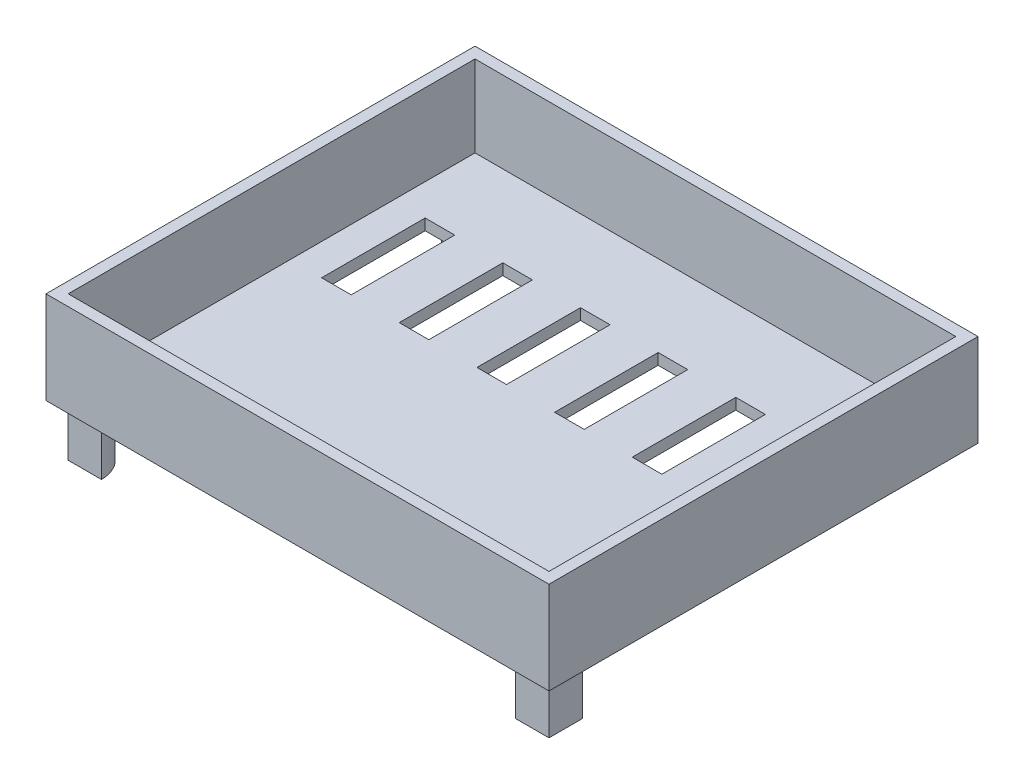
from build123d import *

# Parameters (mm, degrees)
SKETCH2_W                 = 136
SKETCH2_H                 = 136
BOSS_EXTRUDE1_DEPTH       = 25
SKETCH3_W                 = 118
SKETCH3_H                 = 118
CUT_EXTRUDE1_DEPTH        = 22
CUT_EXTRUDE3_DEPTH        = 22
CUT_EXTRUDE4_DEPTH        = 22
SKETCH7_W                 = 29.69848481
SKETCH7_H                 = 30.00387357
BOSS_EXTRUDE2_DEPTH       = 25
BOSS_EXTRUDE3_DEPTH       = 3
CUT_EXTRUDE5_DEPTH        = 23
CUT_EXTRUDE6_DEPTH        = 22
CUT_EXTRUDE7_DEPTH        = 32
BOSS_EXTRUDE6_DEPTH       = 6.36
BOSS_EXTRUDE7_DEPTH       = 6.36
CUT_EXTRUDE9_DEPTH        = 6.36
CUT_EXTRUDE10_DEPTH       = 56.36
BOSS_EXTRUDE8_DEPTH       = 3
BOSS_EXTRUDE9_START       = -20
BOSS_EXTRUDE9_DEPTH       = 2
SKETCH23_W                = 29.69848481
SKETCH23_H                = 2
BOSS_EXTRUDE10_DEPTH      = 1.5
SKETCH24_W                = 10.361394494
SKETCH24_H                = 0.734081985
CUT_EXTRUDE11_DEPTH       = 31.5
BOSS_EXTRUDE11_DEPTH      = 4
BOSS_EXTRUDE12_DEPTH      = 44
CUT_EXTRUDE12_DEPTH       = 50
BOSS_EXTRUDE13_DEPTH      = 3
BOSS_EXTRUDE14_DEPTH      = 22
SKETCH33_W                = 130
SKETCH33_H                = 130
CUT_EXTRUDE13_DEPTH       = 22
CUT_EXTRUDE15_DEPTH       = 12
CUT_EXTRUDE16_DEPTH       = 32
BOSS_EXTRUDE15_DEPTH      = 22
BOSS_EXTRUDE15_DEPTH_BACK = 3
BOSS_EXTRUDE16_DEPTH      = 16.980368
CUT_EXTRUDE17_DEPTH       = 2
BOSS_EXTRUDE17_DEPTH      = 14.980368
CUT_EXTRUDE18_DEPTH       = 1
BOSS_EXTRUDE20_DEPTH      = 13.980368


with BuildPart() as part:
    # Sketch2 → Boss-Extrude1 (new body)
    with BuildSketch(Plane(origin=(0, 0, 0), x_dir=(1, 0, 0), z_dir=(0, 1, 0))):
        with Locations((9.299145299, -9.88034188)):
            Rectangle(SKETCH2_W, SKETCH2_H)
    extrude(amount=BOSS_EXTRUDE1_DEPTH)

    # Sketch3 → Cut-Extrude1 (cut)
    with BuildSketch(Plane(origin=(0, 25, 0), x_dir=(1, 0, 0), z_dir=(0, 1, 0))):
        with Locations((9.299145299, -9.88034188)):
            Rectangle(SKETCH3_W, SKETCH3_H)
    extrude(amount=-CUT_EXTRUDE1_DEPTH, mode=Mode.SUBTRACT)

    # Sketch4 → Cut-Extrude3 (cut)
    with BuildSketch(Plane(origin=(0, 25, 0), x_dir=(1, 0, 0), z_dir=(0, 1, 0))):
        Polygon((77.299145299, -77.88034188), (47.299145299, -77.88034188), (47.299145299, -68.88034188), (56.299145299, -68.88034188), (68.299145299, -56.88034188), (68.299145299, -47.88034188), (77.299145299, -47.88034188), align=None)
    extrude(amount=-CUT_EXTRUDE3_DEPTH, mode=Mode.SUBTRACT)

    # Sketch5 → Cut-Extrude4 (cut)
    with BuildSketch(Plane(origin=(0, 3, 0), x_dir=(1, 0, 0), z_dir=(0, 1, 0))):
        Polygon((68.299145299, -47.88034188), (47.299145299, -68.88034188), (47.299145299, -77.88034188), (77.299145299, -77.88034188), (77.299145299, -47.88034188), align=None)
    extrude(amount=-CUT_EXTRUDE4_DEPTH, mode=Mode.SUBTRACT)

    # Sketch7 → Boss-Extrude2 (add)
    with BuildSketch(Plane(origin=(58.08974359, 0, 58.08974359), x_dir=(0.707106781, 0, -0.707106781), z_dir=(0.707106781, 0, 0.707106781))):
        with Locations((-0.410968044, -12.001936785)):
            Rectangle(SKETCH7_W, SKETCH7_H)
    extrude(amount=BOSS_EXTRUDE2_DEPTH)

    # Sketch8 → Boss-Extrude3 (add)
    with BuildSketch(Plane(origin=(0, 3, 0), x_dir=(1, 0, 0), z_dir=(0, 1, 0))):
        Polygon((47.299145299, -77.88034188), (77.299145299, -47.88034188), (68.299145299, -47.88034188), (47.299145299, -68.88034188), align=None)
    extrude(amount=-BOSS_EXTRUDE3_DEPTH)

    # Sketch9 → Cut-Extrude5 (cut)
    with BuildSketch(Plane(origin=(0, 3, 0), x_dir=(1, 0, 0), z_dir=(0, 1, 0))):
        Polygon((47.299145299, -77.88034188), (38.299145299, -68.88034188), (47.299145299, -68.88034188), align=None)
    extrude(amount=CUT_EXTRUDE5_DEPTH, mode=Mode.SUBTRACT)

    # Sketch10 → Cut-Extrude6 (cut)
    with BuildSketch(Plane(origin=(0, 25, 0), x_dir=(1, 0, 0), z_dir=(0, 1, 0))):
        Polygon((77.299145299, -47.88034188), (68.299145299, -38.88034188), (68.299145299, -47.88034188), align=None)
    extrude(amount=-CUT_EXTRUDE6_DEPTH, mode=Mode.SUBTRACT)

    # Sketch11 → Cut-Extrude7 (cut)
    with BuildSketch(Plane(origin=(-10.790598291, 0, 10.790598291), x_dir=(0.707106781, 0, 0.707106781), z_dir=(-0.707106781, 0, 0.707106781))):
        Polygon((88.51526425, 0), (107.151303219, -18.636038969), (107.151303219, -27.00387357), (82.151303219, -27.00387357), (82.151303219, 0), align=None)
        Polygon((88.51526425, 3), (107.151303219, -15.636038969), (107.151303219, 3), align=None)
    extrude(amount=-CUT_EXTRUDE7_DEPTH, mode=Mode.SUBTRACT)

    # Sketch16 → Boss-Extrude6 (add)
    with BuildSketch(Plane(origin=(-10.790598291, 0, 10.790598291), x_dir=(0.707106781, 0, 0.707106781), z_dir=(-0.707106781, 0, 0.707106781))):
        Polygon((88.51526425, 0), (88.51526425, 3), (107.151303219, -15.636038969), (107.151303219, -18.636038969), align=None)
    extrude(amount=BOSS_EXTRUDE6_DEPTH)

    # Sketch17 → Boss-Extrude7 (add)
    with BuildSketch(Plane(origin=(10.209401709, 0, -10.209401709), x_dir=(-0.707106781, 0, -0.707106781), z_dir=(0.707106781, 0, -0.707106781))):
        Polygon((-88.51526425, 0), (-88.51526425, 3), (-107.151303219, -15.636038969), (-107.151303219, -18.636038969), align=None)
    extrude(amount=BOSS_EXTRUDE7_DEPTH)

    # Sketch18 → Cut-Extrude9 (cut)
    with BuildSketch(Plane(origin=(32.355531967, 45.757632125, 32.355531967), x_dir=(0.866025404, -0.40824829, -0.288675135), z_dir=(0.5, 0.707106781, 0.5))):
        Polygon((51.893180344, -37.364371534), (67.109442444, -58.883415765), (61.91652419, -62.555363477), align=None)
        Polygon((32.474894629, -83.373739388), (37.667812884, -79.701791676), (17.258632528, -61.854695157), align=None)
    extrude(amount=-CUT_EXTRUDE9_DEPTH, mode=Mode.SUBTRACT)

    # Sketch19 → Cut-Extrude10 (cut)
    with BuildSketch(Plane(origin=(-15.287797419, 0, 15.287797419), x_dir=(0.707106781, 0, 0.707106781), z_dir=(-0.707106781, 0, 0.707106781))):
        Polygon((107.151303219, -18.636038969), (107.151303219, -15.636038969), (105.651303219, -17.136038969), align=None)
    extrude(amount=-CUT_EXTRUDE10_DEPTH, mode=Mode.SUBTRACT)

    # Sketch20 → Boss-Extrude8 (add)
    with BuildSketch(Plane.XZ):
        Polygon((-58.700854701, 77.88034188), (47.299145299, 77.88034188), (77.299145299, 47.88034188), (77.299145299, -58.11965812), (-58.700854701, -58.11965812), align=None)
    extrude(amount=-BOSS_EXTRUDE8_DEPTH)



with BuildPart() as body_2:
    # Sketch22 → Boss-Extrude9 (new body)
    with BuildSketch(Plane(origin=(0, 3, 0), x_dir=(1, 0, 0), z_dir=(0, 1, 0)).offset(BOSS_EXTRUDE9_START)):
        Polygon((64.976814829, -86.55801141), (70.906234285, -91.928484844), (91.906234285, -70.928484844), (85.976814829, -65.55801141), align=None)
    extrude(amount=BOSS_EXTRUDE9_DEPTH)


with BuildPart() as part_1:
    add(part.part)

    add(body_2.part)  # Boss-Extrude10 merges body 2
    # Sketch23 → Boss-Extrude10 (add)
    with BuildSketch(Plane(origin=(75.767413119, 0, 75.767413119), x_dir=(-0.707106781, 0, 0.707106781), z_dir=(-0.707106781, 0, -0.707106781))):
        with Locations((0.410968044, -16)):
            Rectangle(SKETCH23_W, SKETCH23_H)
    extrude(amount=BOSS_EXTRUDE10_DEPTH)

    # Sketch24 → Cut-Extrude11 (cut)
    with BuildSketch(Plane(origin=(-13.785543706, 0, 15.220310104), x_dir=(0.741177432, 0, 0.671309179), z_dir=(-0.671309179, 0, 0.741177432))):
        with Locations((109.085839112, -17.367040993)):
            Rectangle(SKETCH24_W, SKETCH24_H)
    extrude(amount=-CUT_EXTRUDE11_DEPTH, mode=Mode.SUBTRACT)

    # Sketch28 → Boss-Extrude11 (add)
    with BuildSketch(Plane(origin=(32.355531967, 45.757632125, 32.355531967), x_dir=(0.866025404, -0.40824829, -0.288675135), z_dir=(0.5, 0.707106781, 0.5))):
        Polygon((17.25539836, -61.856982059), (8.148098637, -53.895706291), (47.339944519, -25.921031992), (51.893180344, -37.364371534), align=None)
    extrude(amount=-BOSS_EXTRUDE11_DEPTH)

    # Sketch29 → Boss-Extrude12 (add)
    with BuildSketch(Plane(origin=(14.709401709, 0, -14.709401709), x_dir=(0.707106781, 0, 0.707106781), z_dir=(-0.707106781, 0, 0.707106781))):
        Polygon((80.058656938, 11.456607312), (75.787342189, 11.456607312), (75.787342189, 3), (82.858410001, 3), align=None)
    extrude(amount=BOSS_EXTRUDE12_DEPTH)

    # Sketch30 → Cut-Extrude12 (cut)
    with BuildSketch(Plane(origin=(0, 25, 0), x_dir=(1, 0, 0), z_dir=(0, 1, 0))):
        Polygon((38.299145299, -68.88034188), (68.299145299, -38.88034188), (77.299145299, -47.88034188), (91.906234285, -70.928484844), (70.906234285, -91.928484844), (47.299145299, -77.88034188), align=None)
    extrude(amount=-CUT_EXTRUDE12_DEPTH, mode=Mode.SUBTRACT)

    # Sketch31 → Boss-Extrude13 (add)
    with BuildSketch(Plane(origin=(0, 3, 0), x_dir=(1, 0, 0), z_dir=(0, 1, 0))):
        Polygon((68.299145299, -38.88034188), (77.299145299, -47.88034188), (77.299145299, -77.88034188), (47.299145299, -77.88034188), (38.299145299, -68.88034188), align=None)
    extrude(amount=-BOSS_EXTRUDE13_DEPTH)

    # Sketch32 → Boss-Extrude14 (add)
    with BuildSketch(Plane(origin=(0, 3, 0), x_dir=(1, 0, 0), z_dir=(0, 1, 0))):
        Polygon((77.299145299, -77.88034188), (77.299145299, -47.88034188), (68.299145299, -38.88034188), (68.299145299, -68.88034188), (38.299145299, -68.88034188), (47.299145299, -77.88034188), align=None)
    extrude(amount=BOSS_EXTRUDE14_DEPTH)

    # Sketch33 → Cut-Extrude13 (cut)
    with BuildSketch(Plane(origin=(0, 25, 0), x_dir=(1, 0, 0), z_dir=(0, 1, 0))):
        with Locations((9.299145299, -9.88034188)):
            Rectangle(SKETCH33_W, SKETCH33_H)
    extrude(amount=-CUT_EXTRUDE13_DEPTH, mode=Mode.SUBTRACT)

    # Sketch34 → Cut-Extrude15 (cut)
    with BuildSketch(Plane(origin=(0, 3, 0), x_dir=(1, 0, 0), z_dir=(0, 1, 0))):
        Polygon((-43.200854701, -14.866207324), (-39.200854701, -14.866207324), (-39.200854701, 13.133792676), (-47.200854701, 13.133792676), (-47.200854701, -14.866207324), align=None)
        Polygon((-22.200854701, -14.865867711), (-18.200854701, -14.865867711), (-18.200854701, 13.133792676), (-26.200854701, 13.133792676), (-26.200854701, -14.865867711), align=None)
        Polygon((-1.200854701, -14.865528099), (2.799145299, -14.865528099), (2.799145299, 13.133792676), (-5.200854701, 13.133792676), (-5.200854701, -14.865528099), align=None)
        Polygon((19.799145299, -14.865188486), (23.799145299, -14.865188486), (23.799145299, 13.133792676), (15.799145299, 13.133792676), (15.799145299, -14.865188486), align=None)
        Polygon((40.799145299, -14.864848873), (44.799145299, -14.864848873), (44.799145299, 13.133792676), (36.799145299, 13.133792676), (36.799145299, -14.864848873), align=None)
        Polygon((61.799145299, -14.86450926), (65.799145299, -14.86450926), (65.799145299, 13.133792676), (57.799145299, 13.133792676), (57.799145299, -14.86450926), align=None)
    extrude(amount=-CUT_EXTRUDE15_DEPTH, mode=Mode.SUBTRACT)

    # Sketch35 → Cut-Extrude16 (cut)
    with BuildSketch(Plane(origin=(0, 25, 0), x_dir=(1, 0, 0), z_dir=(0, 1, 0))):
        Polygon((-55.700854701, 35.11965812), (77.299145299, 35.11965812), (77.299145299, 58.11965812), (-58.700854701, 58.11965812), (-58.700854701, 35.11965812), align=None)
    extrude(amount=-CUT_EXTRUDE16_DEPTH, mode=Mode.SUBTRACT)

    # Sketch36 → Boss-Extrude15 (add, two sides)
    with BuildSketch(Plane(origin=(0, 3, 0), x_dir=(1, 0, 0), z_dir=(0, 1, 0))) as boss_extrude15_sk:
        Polygon((-58.700854701, 35.11965812), (-55.700854701, 35.11965812), (77.299145299, 35.11965812), (77.299145299, 38.11965812), (-58.700854701, 38.11965812), align=None)
    extrude(amount=BOSS_EXTRUDE15_DEPTH)
    extrude(boss_extrude15_sk.sketch, amount=-BOSS_EXTRUDE15_DEPTH_BACK)

    # Sketch37 → Boss-Extrude16 (add)
    with BuildSketch(Plane.XZ):
        with BuildLine():
            Line((-49.704271951, 74.88034188), (-55.700854701, 74.88034188))
            Line((-55.700854701, 74.88034188), (-55.700854701, 68.883759131))
            ThreePointArc((-55.700854701, 68.883759131), (-51.460630375, 70.640117554), (-49.704271951, 74.88034188))
        make_face()
        with BuildLine():
            Line((-55.700854701, -29.11965812), (-55.700854701, -35.11965812))
            Line((-55.700854701, -35.11965812), (-49.700854701, -35.11965812))
            ThreePointArc((-49.700854701, -35.11965812), (-51.458214014, -30.877017433), (-55.700854701, -29.11965812))
        make_face()
    extrude(amount=BOSS_EXTRUDE16_DEPTH)

    # Sketch38 → Cut-Extrude17 (cut)
    with BuildSketch(Plane.XZ.offset(16.980367935)):
        with BuildLine():
            Line((-55.700854701, 74.88034188), (-55.700854701, 68.883759131))
            ThreePointArc((-55.700854701, 68.883759131), (-51.460630375, 70.640117554), (-49.704271951, 74.88034188))
            Line((-49.704271951, 74.88034188), (-55.700854701, 74.88034188))
        make_face()
        with BuildLine():
            Line((-55.700854701, -35.11965812), (-49.700854701, -35.11965812))
            ThreePointArc((-49.700854701, -35.11965812), (-51.458214014, -30.877017433), (-55.700854701, -29.11965812))
            Line((-55.700854701, -29.11965812), (-55.700854701, -35.11965812))
        make_face()
    extrude(amount=-CUT_EXTRUDE17_DEPTH, mode=Mode.SUBTRACT)

    # Sketch39 → Boss-Extrude17 (add)
    with BuildSketch(Plane.XZ):
        with BuildLine():
            Line((68.299145299, 74.88034188), (74.299145299, 74.88034188))
            Line((74.299145299, 74.88034188), (74.299145299, 68.88034188))
            ThreePointArc((74.299145299, 68.88034188), (70.056504612, 70.637701193), (68.299145299, 74.88034188))
        make_face()
    extrude(amount=BOSS_EXTRUDE17_DEPTH)

    # Sketch40 → Cut-Extrude18 (cut)
    with BuildSketch(Plane.XZ.offset(14.980367935)):
        with BuildLine():
            Line((74.299145299, 68.88034188), (74.299145299, 74.88034188))
            Line((74.299145299, 74.88034188), (68.299145299, 74.88034188))
            ThreePointArc((68.299145299, 74.88034188), (70.056504612, 70.637701193), (74.299145299, 68.88034188))
        make_face()
        with BuildLine():
            Line((-49.704271951, 74.88034188), (-55.700854701, 74.88034188))
            Line((-55.700854701, 74.88034188), (-55.700854701, 68.883759131))
            ThreePointArc((-55.700854701, 68.883759131), (-51.460630375, 70.640117554), (-49.704271951, 74.88034188))
        make_face()
        with BuildLine():
            Line((-55.700854701, -29.11965812), (-55.700854701, -35.11965812))
            Line((-55.700854701, -35.11965812), (-49.700854701, -35.11965812))
            ThreePointArc((-49.700854701, -35.11965812), (-51.458214014, -30.877017433), (-55.700854701, -29.11965812))
        make_face()
    extrude(amount=-CUT_EXTRUDE18_DEPTH, mode=Mode.SUBTRACT)

    # Sketch42 → Boss-Extrude20 (add)
    with BuildSketch(Plane(origin=(0, -13.980367935, 0), x_dir=(-1, 0, 0), z_dir=(0, -1, 0))):
        with BuildLine():
            Line((55.700854701, -65.88034188), (55.700854701, -74.88034188))
            Line((55.700854701, -74.88034188), (46.700854701, -74.88034188))
            ThreePointArc((46.700854701, -74.88034188), (49.33689367, -68.51638085), (55.700854701, -65.88034188))
        make_face()
        with BuildLine():
            Line((55.700854701, 26.11965812), (55.700854701, 35.11965812))
            Line((55.700854701, 35.11965812), (46.700854701, 35.11965812))
            ThreePointArc((46.700854701, 35.11965812), (49.33689367, 28.755697089), (55.700854701, 26.11965812))
        make_face()
        with BuildLine():
            Line((-65.299145299, -74.88034188), (-74.299145299, -74.88034188))
            Line((-74.299145299, -74.88034188), (-74.299145299, -65.88034188))
            ThreePointArc((-74.299145299, -65.88034188), (-67.935184268, -68.51638085), (-65.299145299, -74.88034188))
        make_face()
    extrude(amount=-BOSS_EXTRUDE20_DEPTH)


solid = part_1.part
